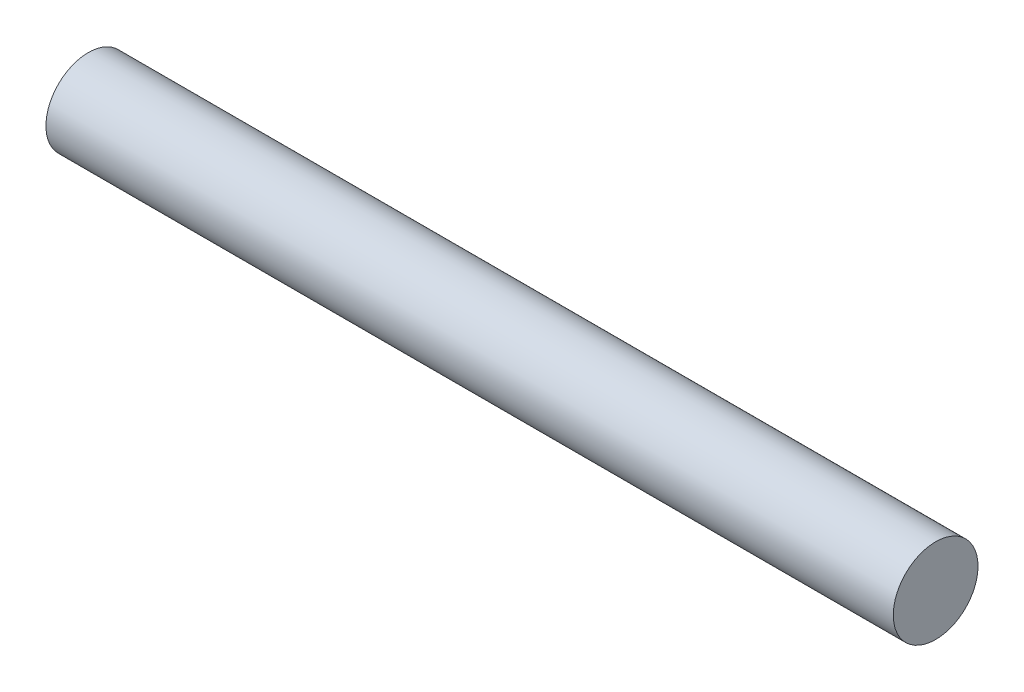
from build123d import *

# Parameters (mm, degrees)
SKETCH1_R      = 10
EXTRUDE1_DEPTH = 200


with BuildPart() as part:
    # Sketch1 → Extrude1 (new body)
    with BuildSketch(Plane(origin=(0, 0, 0), x_dir=(0, 0, -1), z_dir=(1, 0, 0))):
        Circle(SKETCH1_R)
    extrude(amount=EXTRUDE1_DEPTH)


solid = part.part
